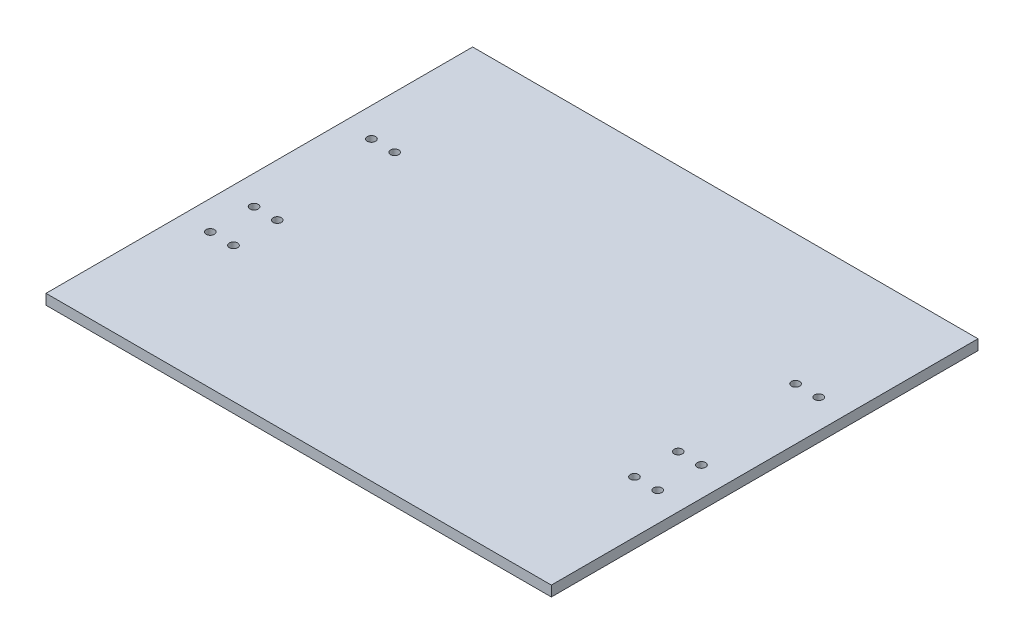
from build123d import *

# Parameters (mm, degrees)
SKETCH1_W           = 119
SKETCH1_H           = 103
BOSS_EXTRUDE1_DEPTH = 2.5
SKETCH2_R           = 1
CUT_EXTRUDE1_DEPTH  = 10
SKETCH3_W           = 103
SKETCH3_H           = 2.5
BOSS_EXTRUDE2_DEPTH = 1.5
SKETCH4_W           = 103
SKETCH4_H           = 2.5
BOSS_EXTRUDE3_DEPTH = 1.5


with BuildPart() as part:
    # Sketch1 → Boss-Extrude1 (new body)
    with BuildSketch(Plane(origin=(0, 0, 0), x_dir=(1, 0, 0), z_dir=(0, 1, 0))):
        Rectangle(SKETCH1_W, SKETCH1_H)
    extrude(amount=BOSS_EXTRUDE1_DEPTH)

    # Sketch2 → Cut-Extrude1 (cut)
    with BuildSketch(Plane.XZ):
        with Locations((-54, -20.06)):
            Circle(SKETCH2_R)
        with Locations((-54, 8.27)):
            Circle(SKETCH2_R)
        with Locations((-54, 18.84)):
            Circle(SKETCH2_R)
        with Locations((54, -20.06)):
            Circle(SKETCH2_R)
        with Locations((54, 8.27)):
            Circle(SKETCH2_R)
        with Locations((54, 18.84)):
            Circle(SKETCH2_R)
        with Locations((-48.4, 18.84)):
            Circle(SKETCH2_R)
        with Locations((-48.4, -20.06)):
            Circle(SKETCH2_R)
        with Locations((-48.4, 8.27)):
            Circle(SKETCH2_R)
        with Locations((48.4, -20.06)):
            Circle(SKETCH2_R)
        with Locations((48.4, 8.27)):
            Circle(SKETCH2_R)
        with Locations((48.4, 18.84)):
            Circle(SKETCH2_R)
    extrude(amount=-CUT_EXTRUDE1_DEPTH, mode=Mode.SUBTRACT)

    # Sketch3 → Boss-Extrude2 (add)
    with BuildSketch(Plane.ZY.offset(59.5)):
        with Locations((0, 1.25)):
            Rectangle(SKETCH3_W, SKETCH3_H)
    extrude(amount=BOSS_EXTRUDE2_DEPTH)

    # Sketch4 → Boss-Extrude3 (add)
    with BuildSketch(Plane(origin=(59.5, 0, 0), x_dir=(0, 0, -1), z_dir=(1, 0, 0))):
        with Locations((0, 1.25)):
            Rectangle(SKETCH4_W, SKETCH4_H)
    extrude(amount=BOSS_EXTRUDE3_DEPTH)


solid = part.part
